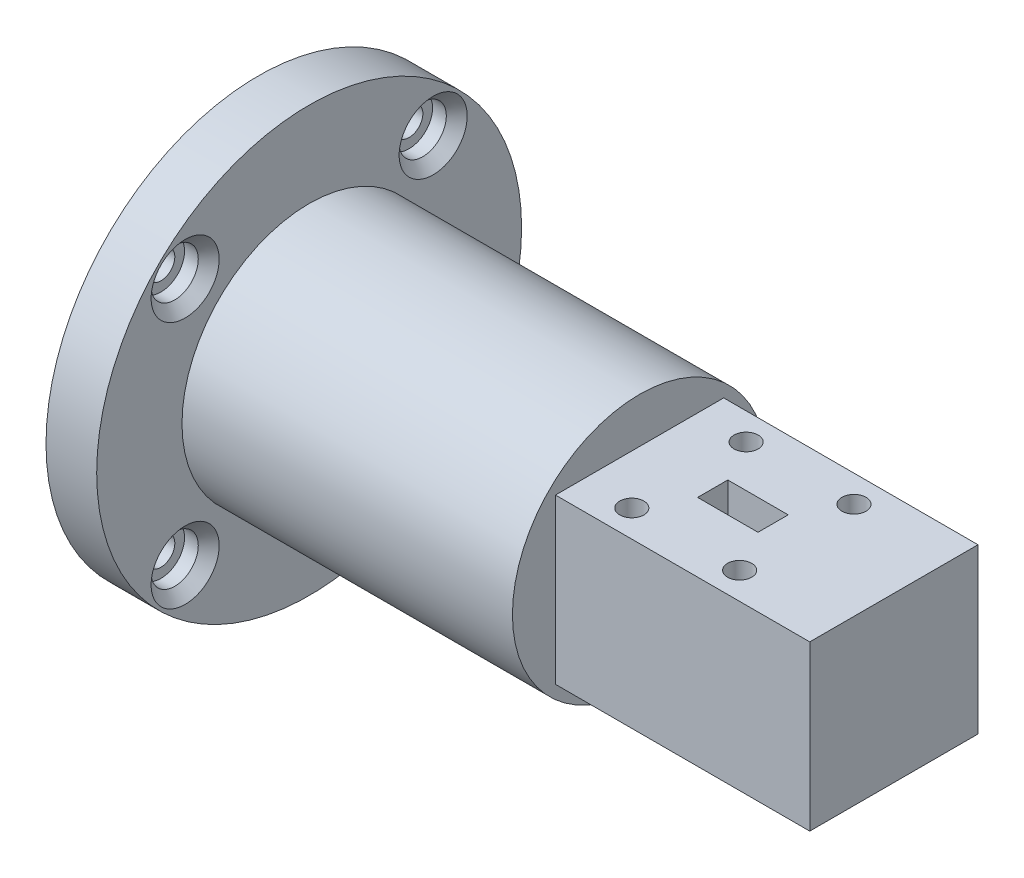
from build123d import *

# Parameters (mm, degrees)
SKETCH1_R                                     = 25.019
BOSS_EXTRUDE1_DEPTH                           = 5.969
SKETCH2_R                                     = 14.9733
BOSS_EXTRUDE2_DEPTH                           = 38.9128
SKETCH3_W                                     = 19.812
SKETCH3_H                                     = 19.304
BOSS_EXTRUDE3_DEPTH                           = 29.9466
CBORE_FOR_4_SOCKET_HEAD_CAP_SCREW1_AT_2_COUNT = 2
CBORE_FOR_4_SOCKET_HEAD_CAP_SCREW1_AT_2_PITCH = 29.21
CBORE_FOR_4_SOCKET_HEAD_CAP_SCREW1_AT_3_COUNT = 2
CBORE_FOR_4_SOCKET_HEAD_CAP_SCREW1_AT_3_PITCH = 29.21
CBORE_FOR_4_SOCKET_HEAD_CAP_SCREW1_AT_4_COUNT = 2
CBORE_FOR_4_SOCKET_HEAD_CAP_SCREW1_AT_4_PITCH = 41.309178157
SKETCH6_R                                     = 1.4224
SKETCH6_W                                     = 7.112
SKETCH6_H                                     = 3.556
CUT_EXTRUDE1_DEPTH                            = 5.08
SKETCH7_R                                     = 1.4224
SKETCH7_W                                     = 7.112
SKETCH7_H                                     = 3.556
CUT_EXTRUDE2_DEPTH                            = 5.08
SKETCH8_R                                     = 4.73075
CUT_EXTRUDE3_DEPTH                            = 12.7


with BuildPart() as part:
    # Sketch1 → Boss-Extrude1 (new body)
    with BuildSketch(Plane(origin=(0, 0, 0), x_dir=(0, 0, -1), z_dir=(1, 0, 0))):
        Circle(SKETCH1_R)
    extrude(amount=BOSS_EXTRUDE1_DEPTH)

    # Sketch2 → Boss-Extrude2 (add)
    with BuildSketch(Plane(origin=(5.969, 0, 0), x_dir=(0, 0, -1), z_dir=(1, 0, 0))):
        Circle(SKETCH2_R)
    extrude(amount=BOSS_EXTRUDE2_DEPTH)

    # Sketch3 → Boss-Extrude3 (add)
    with BuildSketch(Plane(origin=(44.8818, 0, 0), x_dir=(0, 0, -1), z_dir=(1, 0, 0))):
        Rectangle(SKETCH3_W, SKETCH3_H)
    extrude(amount=BOSS_EXTRUDE3_DEPTH)

    # Sketch4 → CBORE for #4 Socket Head Cap Screw1 (revolve, cut)
    with BuildSketch(Plane(origin=(5.969, 14.605, -14.605), x_dir=(0, 0, -1), z_dir=(0, 1, 0))):
        Polygon((0, 0), (0, 5.969), (1.63195, 5.969), (1.63195, 2.8448), (2.77876, 2.8448), (2.77876, 1.22936), (4.00812, 0), align=None)
    cbore_for_4_socket_head_cap_screw1 = revolve(axis=Axis((12.319, 14.605, -14.605), (-1, 0, 0)), mode=Mode.SUBTRACT)

    # CBORE for #4 Socket Head Cap Screw1 at 2: CBORE for #4 Socket Head Cap Screw1 ×2
    with Locations(*[(0, 0, i * CBORE_FOR_4_SOCKET_HEAD_CAP_SCREW1_AT_2_PITCH) for i in range(1, CBORE_FOR_4_SOCKET_HEAD_CAP_SCREW1_AT_2_COUNT)]):
        add(cbore_for_4_socket_head_cap_screw1, mode=Mode.SUBTRACT)

    # CBORE for #4 Socket Head Cap Screw1 at 3: CBORE for #4 Socket Head Cap Screw1 ×2
    with Locations(*[(0, -i * CBORE_FOR_4_SOCKET_HEAD_CAP_SCREW1_AT_3_PITCH, 0) for i in range(1, CBORE_FOR_4_SOCKET_HEAD_CAP_SCREW1_AT_3_COUNT)]):
        add(cbore_for_4_socket_head_cap_screw1, mode=Mode.SUBTRACT)

    # CBORE for #4 Socket Head Cap Screw1 at 4: CBORE for #4 Socket Head Cap Screw1 ×2
    with Locations(*[Vector(0, -0.707106781, 0.707106781) * (i * CBORE_FOR_4_SOCKET_HEAD_CAP_SCREW1_AT_4_PITCH) for i in range(1, CBORE_FOR_4_SOCKET_HEAD_CAP_SCREW1_AT_4_COUNT)]):
        add(cbore_for_4_socket_head_cap_screw1, mode=Mode.SUBTRACT)

    # Sketch6 → Cut-Extrude1 (cut)
    with BuildSketch(Plane(origin=(0, 9.652, 0), x_dir=(1, 0, 0), z_dir=(0, 1, 0))):
        with Locations((63.3984, 6.731)):
            Circle(SKETCH6_R)
        with Locations((50.6984, 6.731)):
            Circle(SKETCH6_R)
        with Locations((50.6984, -6.731)):
            Circle(SKETCH6_R)
        with Locations((63.3984, -6.731)):
            Circle(SKETCH6_R)
        with Locations((57.0484, 0)):
            Rectangle(SKETCH6_W, SKETCH6_H)
    extrude(amount=-CUT_EXTRUDE1_DEPTH, mode=Mode.SUBTRACT)

    # Sketch7 → Cut-Extrude2 (cut)
    with BuildSketch(Plane(origin=(0, 0, -9.906), x_dir=(-1, 0, 0), z_dir=(0, 0, -1))):
        with Locations((-71.6534, 6.731)):
            Circle(SKETCH7_R)
        with Locations((-58.9534, 6.731)):
            Circle(SKETCH7_R)
        with Locations((-58.9534, -6.731)):
            Circle(SKETCH7_R)
        with Locations((-71.6534, -6.731)):
            Circle(SKETCH7_R)
        with Locations((-65.3034, 0)):
            Rectangle(SKETCH7_W, SKETCH7_H)
    extrude(amount=-CUT_EXTRUDE2_DEPTH, mode=Mode.SUBTRACT)

    # Sketch8 → Cut-Extrude3 (cut)
    with BuildSketch(Plane.ZY):
        Circle(SKETCH8_R)
    extrude(amount=-CUT_EXTRUDE3_DEPTH, mode=Mode.SUBTRACT)


solid = part.part
